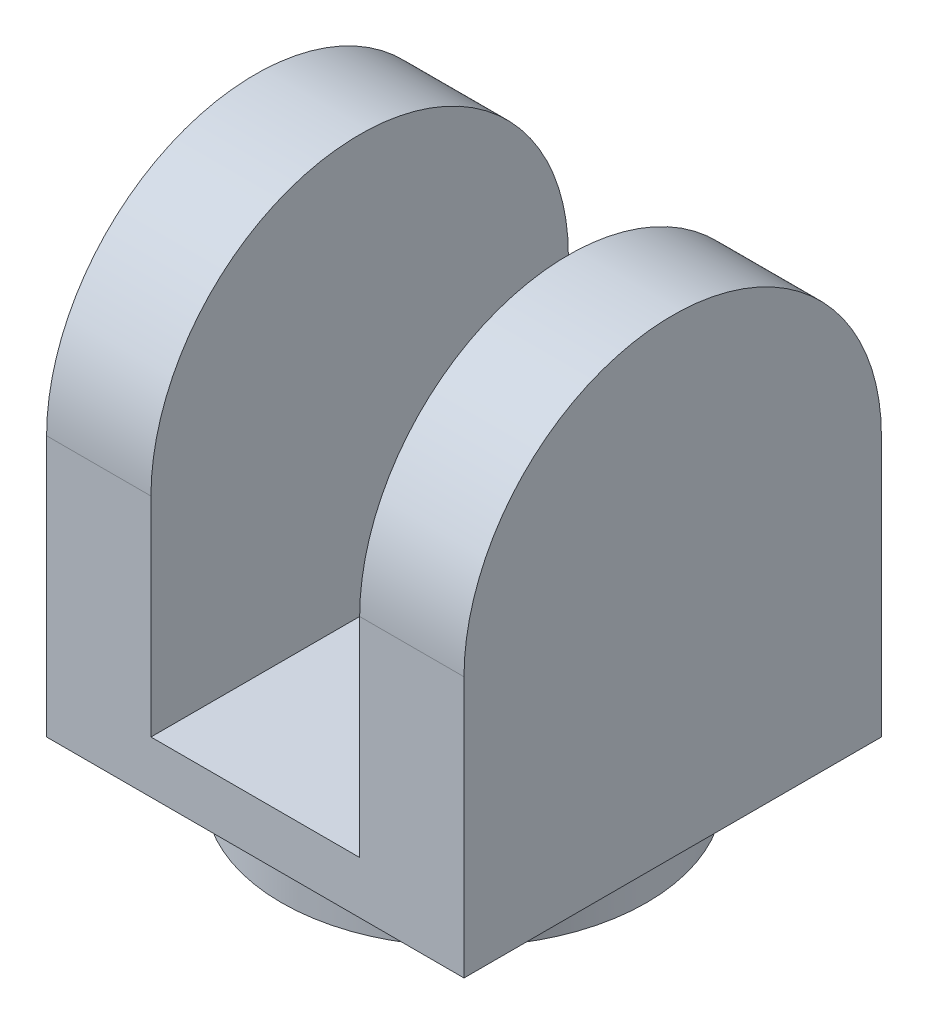
from build123d import *

# Parameters (mm, degrees)
SKETCH_1_R          = 7
EXTRUDE_1_DEPTH     = 2
SKETCH_2_W          = 16
SKETCH_2_H          = 16
EXTRUDE_2_DEPTH     = 18
SKETCH_3_W          = 8
SKETCH_3_H          = 16
CUT_EXTRUDE_1_DEPTH = 16
CUT_EXTRUDE_2_DEPTH = 16


with BuildPart() as part:
    # 草图1 → 凸台-拉伸1 (new body)
    with BuildSketch(Plane(origin=(0, 0, 0), x_dir=(1, 0, 0), z_dir=(0, 1, 0))):
        Circle(SKETCH_1_R)
    extrude(amount=EXTRUDE_1_DEPTH)

    # 草图2 → 凸台-拉伸2 (add)
    with BuildSketch(Plane(origin=(0, 2, 0), x_dir=(1, 0, 0), z_dir=(0, 1, 0))):
        Rectangle(SKETCH_2_W, SKETCH_2_H)
    extrude(amount=EXTRUDE_2_DEPTH)

    # 草图3 → 切除-拉伸1 (cut)
    with BuildSketch(Plane.XY.offset(8)):
        with Locations((0, 12)):
            Rectangle(SKETCH_3_W, SKETCH_3_H)
    extrude(amount=-CUT_EXTRUDE_1_DEPTH, mode=Mode.SUBTRACT)

    # 草图4 → 切除-拉伸2 (cut)
    with BuildSketch(Plane(origin=(8, 0, 0), x_dir=(0, 0, -1), z_dir=(1, 0, 0))):
        with BuildLine():
            Line((-8, 12), (-8, 21.557868838))
            Line((-8, 21.557868838), (8, 21.557868838))
            Line((8, 21.557868838), (8, 12))
            ThreePointArc((8, 12), (0, 20), (-8, 12))
        make_face()
    extrude(amount=-CUT_EXTRUDE_2_DEPTH, mode=Mode.SUBTRACT)


solid = part.part
